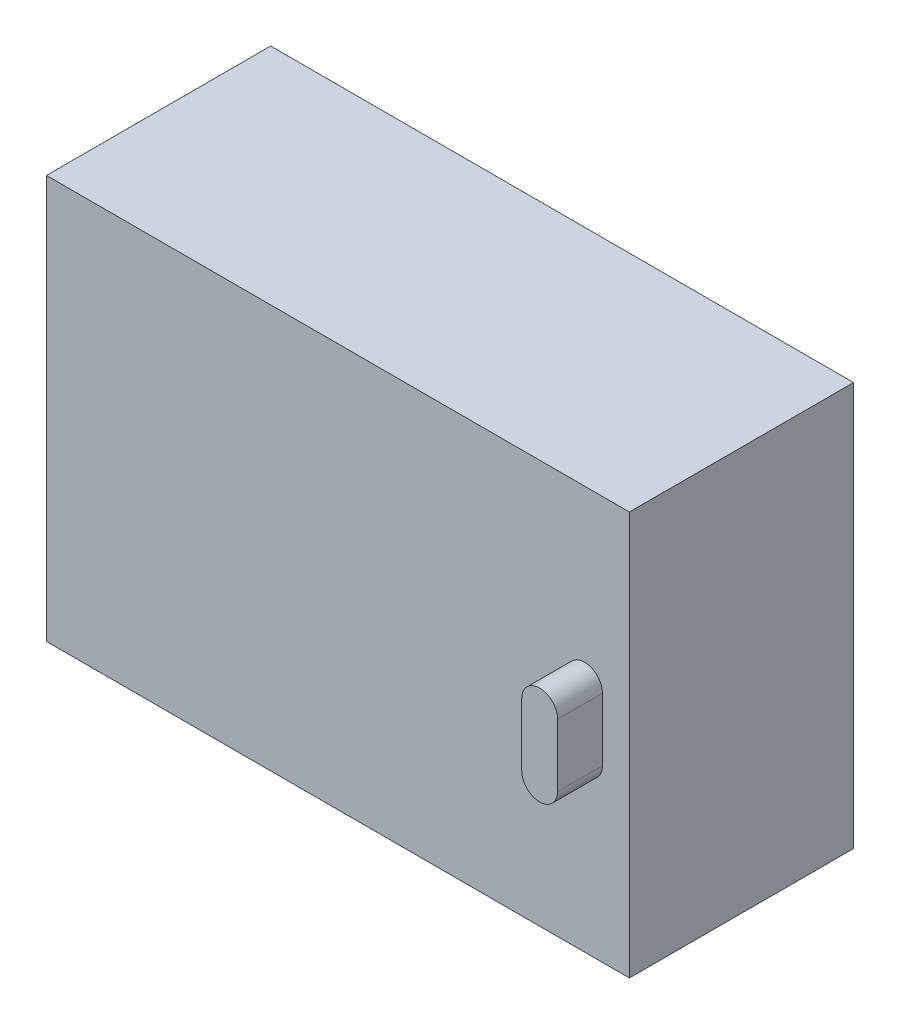
from build123d import *

# Parameters (mm, degrees)
SKETCH_1_W      = 50
SKETCH_1_H      = 90
EXTRUDE_1_DEPTH = 130
EXTRUDE_2_DEPTH = 10


with BuildPart() as part:
    # Эскиз1 → Бобышка-Вытянуть1 (new body)
    with BuildSketch(Plane(origin=(0, 0, 0), x_dir=(0, 0, -1), z_dir=(1, 0, 0))):
        with Locations((25, 45)):
            Rectangle(SKETCH_1_W, SKETCH_1_H)
    extrude(amount=-EXTRUDE_1_DEPTH)

    # Эскиз2 → Бобышка-Вытянуть2 (add)
    with BuildSketch(Plane.XY):
        with BuildLine():
            Line((-14, 38), (-14, 52))
            ThreePointArc((-14, 52), (-10, 56), (-6, 52))
            Line((-6, 52), (-6, 38))
            ThreePointArc((-6, 38), (-10, 34), (-14, 38))
        make_face()
    extrude(amount=EXTRUDE_2_DEPTH)


solid = part.part
